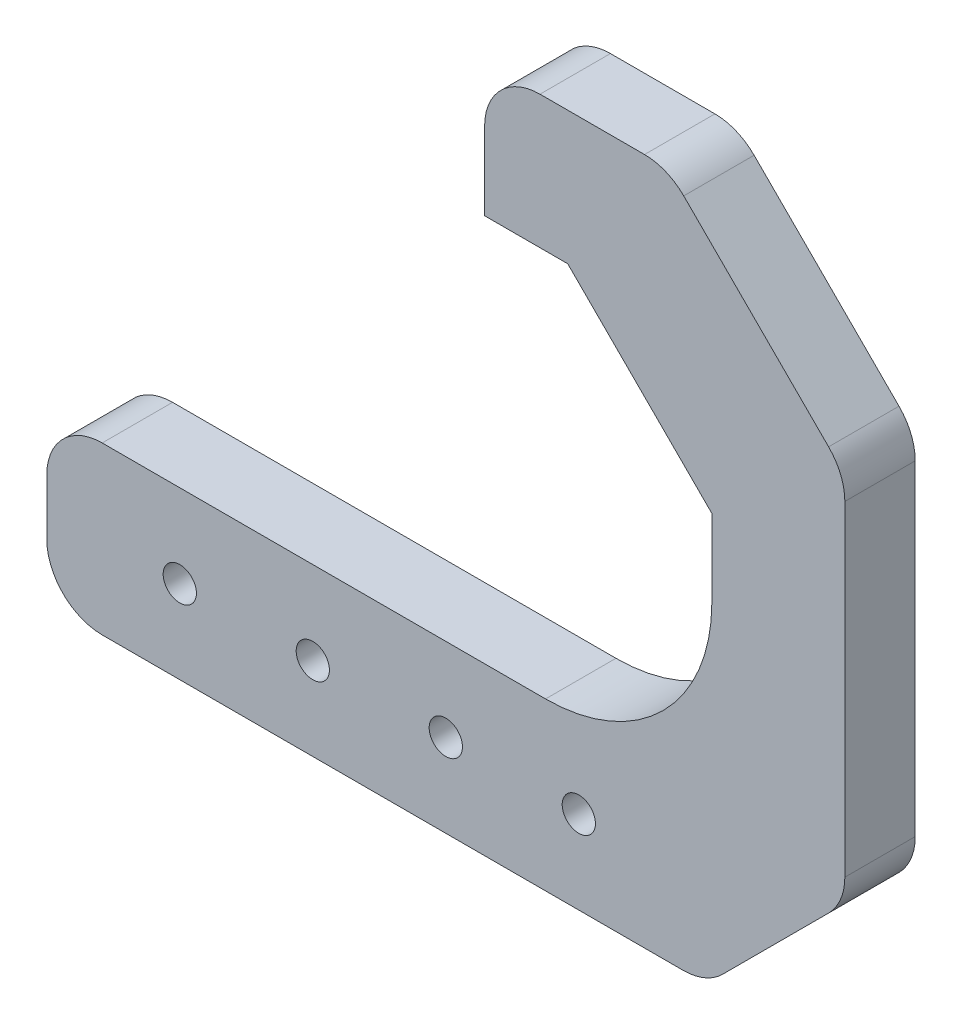
from build123d import *

# Parameters (mm, degrees)
SKETCH1_W           = 60
SKETCH1_H           = 15
SKETCH1_R           = 1.5
BOSS_EXTRUDE1_DEPTH = 6.35
FILLET1_R           = 15
CHAMFER1_SIZE       = 13
FILLET3_R           = 5
CHAMFER2_SIZE       = 12.5
CHAMFER3_SIZE       = 16
FILLET4_R           = 5
FILLET5_R           = 5


with BuildPart() as part:
    # Sketch1 → Boss-Extrude1 (new body)
    with BuildSketch(Plane.XY):
        with Locations((30, 7.5)):
            Rectangle(SKETCH1_W, SKETCH1_H)
        with Locations((12, 7.5)):
            Circle(SKETCH1_R, mode=Mode.SUBTRACT)
        with Locations((24, 7.5)):
            Circle(SKETCH1_R, mode=Mode.SUBTRACT)
        with Locations((36, 7.5)):
            Circle(SKETCH1_R, mode=Mode.SUBTRACT)
        with Locations((48, 7.5)):
            Circle(SKETCH1_R, mode=Mode.SUBTRACT)
        Polygon((60, 15), (60, 0), (72, 0), (72, 50), (60, 50), align=None)
        Polygon((39.5, 50), (60, 50), (72, 50), (72, 62), (39.5, 62), align=None)
    extrude(amount=BOSS_EXTRUDE1_DEPTH)

    # Fillet1
    fillet1_edges = [part.edges().sort_by_distance(p)[0] for p in [
        (60, 15, 3.175),
    ]]
    fillet(fillet1_edges, radius=FILLET1_R)

    # Chamfer1
    chamfer1_edges = [part.edges().sort_by_distance(p)[0] for p in [
        (60, 50, 3.175),
    ]]
    chamfer(chamfer1_edges, length=CHAMFER1_SIZE)

    # Fillet3
    fillet3_edges = [part.edges().sort_by_distance(p)[0] for p in [
        (39.5, 62, 3.175),
    ]]
    fillet(fillet3_edges, radius=FILLET3_R)

    # Chamfer2
    chamfer2_edges = [part.edges().sort_by_distance(p)[0] for p in [
        (72, 0, 3.175),
    ]]
    chamfer(chamfer2_edges, length=CHAMFER2_SIZE)

    # Chamfer3
    chamfer3_edges = [part.edges().sort_by_distance(p)[0] for p in [
        (72, 62, 3.175),
    ]]
    chamfer(chamfer3_edges, length=CHAMFER3_SIZE)

    # Fillet4
    fillet4_edges = [part.edges().sort_by_distance(p)[0] for p in [
        (72, 12.5, 3.175),
        (59.5, 0, 3.175),
        (56, 62, 3.175),
        (72, 46, 3.175),
    ]]
    fillet(fillet4_edges, radius=FILLET4_R)

    # Fillet5
    fillet5_edges = [part.edges().sort_by_distance(p)[0] for p in [
        (0, 0, 3.175),
        (0, 15, 3.175),
    ]]
    fillet(fillet5_edges, radius=FILLET5_R)


solid = part.part
